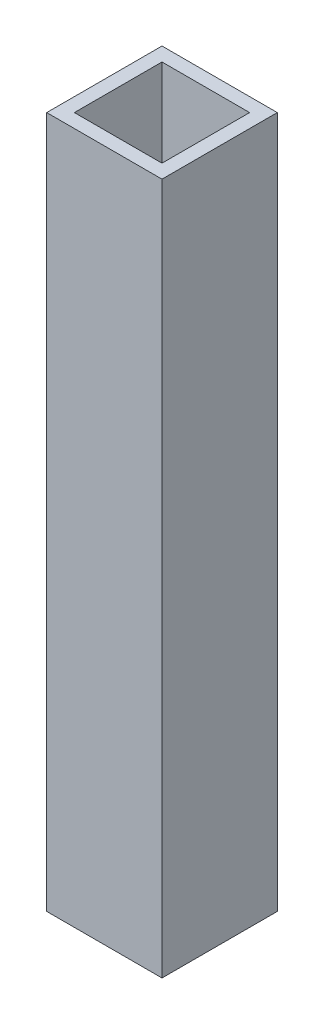
from build123d import *

# Parameters (mm, degrees)
SKETCH1_W           = 25
SKETCH1_H           = 25
SKETCH1_W_2         = 19
SKETCH1_H_2         = 19
BOSS_EXTRUDE1_DEPTH = 150


with BuildPart() as part:
    # Sketch1 → Boss-Extrude1 (new body)
    with BuildSketch(Plane(origin=(0, 0, 0), x_dir=(1, 0, 0), z_dir=(0, 1, 0))):
        Rectangle(SKETCH1_W, SKETCH1_H)
        Rectangle(SKETCH1_W_2, SKETCH1_H_2, mode=Mode.SUBTRACT)
    extrude(amount=BOSS_EXTRUDE1_DEPTH)


solid = part.part
